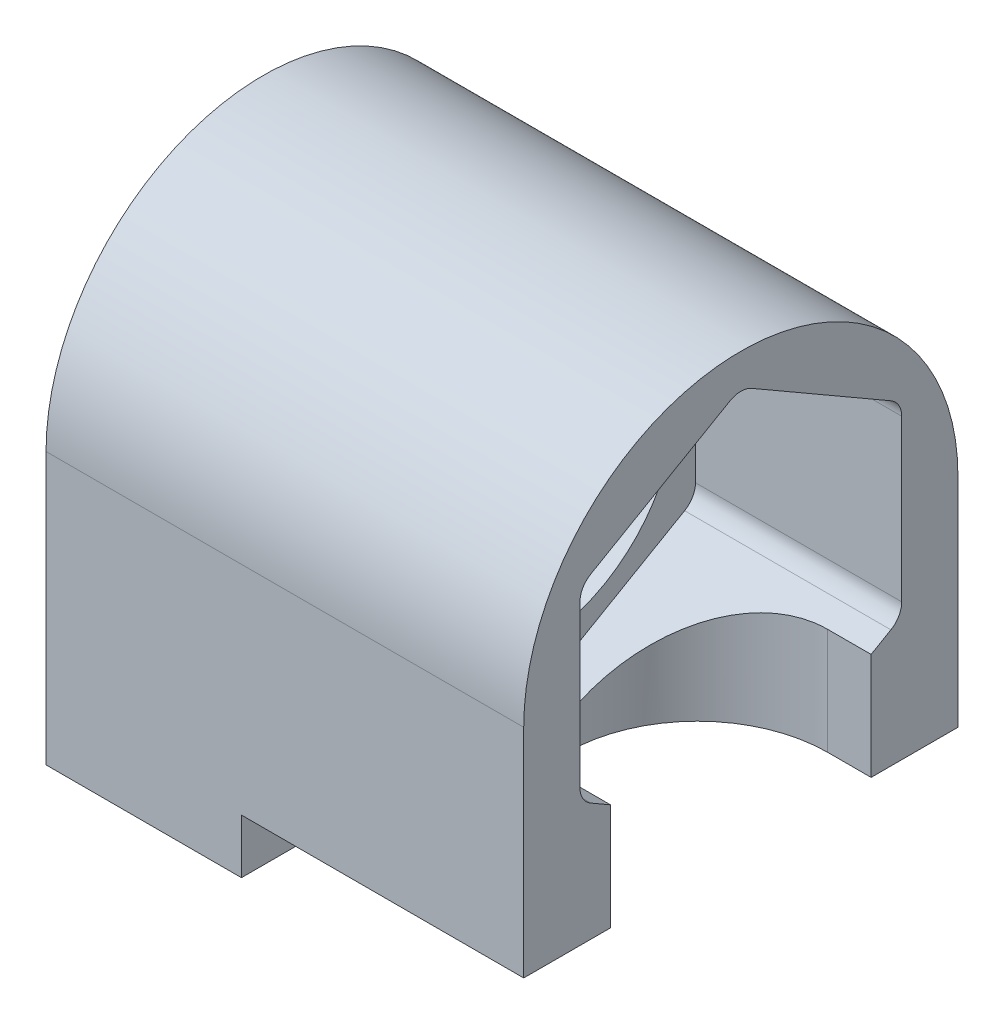
from build123d import *

# Parameters (mm, degrees)
SKIZZE1_R                       = 6.5
AUFSATZ_LINEAR_AUSTRAGEN1_DEPTH = 22
SCHNITT_LINEAR_AUSTRAGEN1_DEPTH = 9.5
SKIZZE3_R                       = 2.75
SCHNITT_LINEAR_AUSTRAGEN2_DEPTH = 6
SCHNITT_LINEAR_AUSTRAGEN3_REACH = 24.5
SKIZZE5_W                       = 13
SKIZZE5_H                       = 20
SCHNITT_LINEAR_AUSTRAGEN4_DEPTH = 2.5


with BuildPart() as part:
    # Skizze1 → Aufsatz-Linear austragen1 (new body)
    with BuildSketch(Plane(origin=(0, 0, 0), x_dir=(0, 0, -1), z_dir=(1, 0, 0))):
        with BuildLine():
            Line((-10, 0), (-10, -12.5))
            Line((-10, -12.5), (10, -12.5))
            Line((10, -12.5), (10, 0))
            ThreePointArc((10, 0), (0, 10), (-10, 0))
        make_face()
        Circle(SKIZZE1_R, mode=Mode.SUBTRACT)
    extrude(amount=AUFSATZ_LINEAR_AUSTRAGEN1_DEPTH)

    # Skizze2 → Schnitt-Linear austragen1 (cut)
    with BuildSketch(Plane(origin=(22, 0, 0), x_dir=(0, 0, -1), z_dir=(1, 0, 0))):
        with BuildLine():
            Line((7.410637894, -3.701183514), (7.410637894, 3.701183514))
            ThreePointArc((7.410637894, 3.701183514), (7.276663298, 4.201183514), (6.910637894, 4.567208918))
            Line((6.910637894, 4.567208918), (0.5, 8.268392432))
            ThreePointArc((0.5, 8.268392432), (0, 8.402367028), (-0.5, 8.268392432))
            Line((-0.5, 8.268392432), (-6.910637894, 4.567208918))
            ThreePointArc((-6.910637894, 4.567208918), (-7.276663298, 4.201183514), (-7.410637894, 3.701183514))
            Line((-7.410637894, 3.701183514), (-7.410637894, -3.701183514))
            ThreePointArc((-7.410637894, -3.701183514), (-7.276663298, -4.201183514), (-6.910637894, -4.567208918))
            Line((-6.910637894, -4.567208918), (-0.5, -8.268392432))
            ThreePointArc((-0.5, -8.268392432), (0, -8.402367028), (0.5, -8.268392432))
            Line((0.5, -8.268392432), (6.910637894, -4.567208918))
            ThreePointArc((6.910637894, -4.567208918), (7.276663298, -4.201183514), (7.410637894, -3.701183514))
        make_face()
    extrude(amount=-SCHNITT_LINEAR_AUSTRAGEN1_DEPTH, mode=Mode.SUBTRACT)

    # Skizze3 → Schnitt-Linear austragen2 (cut)
    with BuildSketch(Plane.XZ.offset(12.5)):
        with Locations((5, 5)):
            Circle(SKIZZE3_R)
        with Locations((5, -5)):
            Circle(SKIZZE3_R)
    extrude(amount=-SCHNITT_LINEAR_AUSTRAGEN2_DEPTH, mode=Mode.SUBTRACT)

    # Skizze4 → Schnitt-Linear austragen3 (cut, up to next)
    with BuildSketch(Plane.XZ.offset(12.5), mode=Mode.PRIVATE) as schnitt_linear_austragen3_sk1:
        with BuildLine():
            Line((20, 6), (22, 6))
            Line((22, 6), (22, -6))
            Line((22, -6), (20, -6))
            ThreePointArc((20, -6), (14, 0), (20, 6))
        make_face()
    schnitt_linear_austragen3_tool1 = extrude(schnitt_linear_austragen3_sk1.sketch, amount=-SCHNITT_LINEAR_AUSTRAGEN3_REACH, mode=Mode.PRIVATE) & part.part
    add(schnitt_linear_austragen3_tool1.solids().sort_by_distance((18.510217, -12.5, 0))[0], mode=Mode.SUBTRACT)

    # Skizze5 → Schnitt-Linear austragen4 (cut)
    with BuildSketch(Plane.XZ.offset(12.5)):
        with Locations((15.5, 0)):
            Rectangle(SKIZZE5_W, SKIZZE5_H)
    extrude(amount=-SCHNITT_LINEAR_AUSTRAGEN4_DEPTH, mode=Mode.SUBTRACT)


solid = part.part
